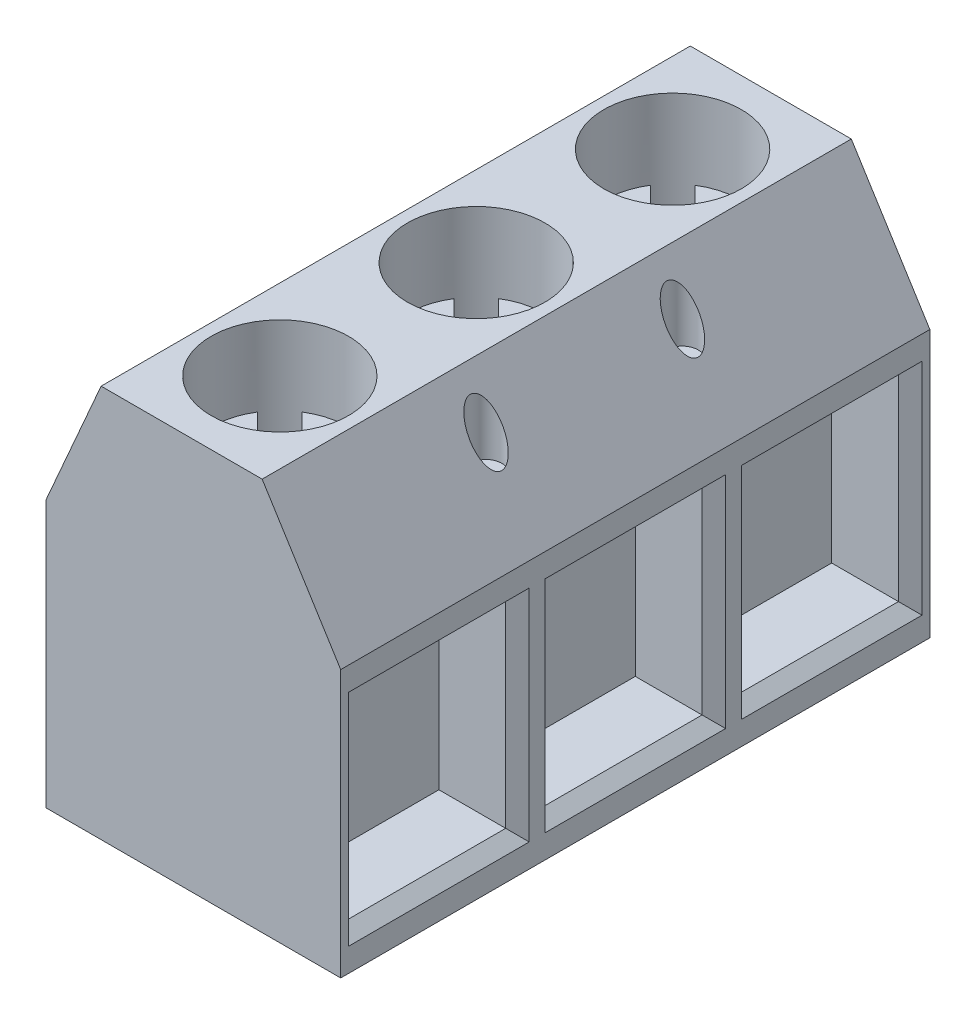
from build123d import *

# Parameters (mm, degrees)
BOSS_EXTRUDE1_DEPTH = 7.5
SKETCH2_W           = 1
SKETCH2_H           = 1
BOSS_EXTRUDE2_DEPTH = 1
SKETCH3_W           = 4
SKETCH3_H           = 5
CUT_EXTRUDE1_DEPTH  = 2
SKETCH4_R           = 1.75
SKETCH4_R_2         = 0.4
CUT_EXTRUDE2_DEPTH  = 2
CUT_EXTRUDE3_DEPTH  = 0.5
CHAMFER1_SIZE       = 0.3


with BuildPart() as part:
    # Sketch1 → Boss-Extrude1 (new body, symmetric)
    with BuildSketch(Plane.XY):
        Polygon((-3.75, 0), (3.75, 0), (3.75, 6.8), (1.75, 10), (-2.35, 10), (-3.75, 6.8), align=None)
    extrude(amount=BOSS_EXTRUDE1_DEPTH, both=True)

    # Sketch2 → Boss-Extrude2 (add)
    with BuildSketch(Plane.XZ):
        with Locations((0.45, 5)):
            Rectangle(SKETCH2_W, SKETCH2_H)
        with Locations((0.45, 0)):
            Rectangle(SKETCH2_W, SKETCH2_H)
        with Locations((0.45, -5)):
            Rectangle(SKETCH2_W, SKETCH2_H)
    extrude(amount=BOSS_EXTRUDE2_DEPTH)

    # Sketch3 → Cut-Extrude1 (cut)
    with BuildSketch(Plane(origin=(3.75, 0, 0), x_dir=(0, 0, -1), z_dir=(1, 0, 0))):
        with Locations((-5, 3.4)):
            Rectangle(SKETCH3_W, SKETCH3_H)
        with Locations((0, 3.4)):
            Rectangle(SKETCH3_W, SKETCH3_H)
        with Locations((5, 3.4)):
            Rectangle(SKETCH3_W, SKETCH3_H)
    extrude(amount=-CUT_EXTRUDE1_DEPTH, mode=Mode.SUBTRACT)

    # Sketch4 → Cut-Extrude2 (cut)
    with BuildSketch(Plane(origin=(0, 10, 0), x_dir=(1, 0, 0), z_dir=(0, 1, 0))):
        with Locations((-0.3, 5)):
            Circle(SKETCH4_R)
        with Locations((-0.3, 0)):
            Circle(SKETCH4_R)
        with Locations((-0.3, -5)):
            Circle(SKETCH4_R)
        with Locations((2.45, 2.5)):
            Circle(SKETCH4_R_2)
        with Locations((2.45, -2.5)):
            Circle(SKETCH4_R_2)
        with Locations((-3.05, 2.5)):
            Circle(SKETCH4_R_2)
        with Locations((-3.05, -2.5)):
            Circle(SKETCH4_R_2)
    extrude(amount=-CUT_EXTRUDE2_DEPTH, mode=Mode.SUBTRACT)

    # Sketch5 → Cut-Extrude3 (cut)
    with BuildSketch(Plane(origin=(0, 8, 0), x_dir=(1, 0, 0), z_dir=(0, 1, 0))):
        with BuildLine():
            Line((-1.221836, 1.487521), (-0.3, 0.565685))
            Line((-0.3, 0.565685), (0.124264, 0.989949))
            Line((0.124264, 0.989949), (0.689949, 0.424264))
            Line((0.689949, 0.424264), (0.265685, 0))
            Line((0.265685, 0), (1.187521, -0.921836))
            ThreePointArc((1.187521, -0.921836), (0.937437, -1.237437), (0.621836, -1.487521))
            Line((0.621836, -1.487521), (-0.3, -0.565685))
            Line((-0.3, -0.565685), (-0.724264, -0.989949))
            Line((-0.724264, -0.989949), (-1.289949, -0.424264))
            Line((-1.289949, -0.424264), (-0.865685, 0))
            Line((-0.865685, 0), (-1.787521, 0.921836))
            ThreePointArc((-1.787521, 0.921836), (-1.537437, 1.237437), (-1.221836, 1.487521))
        make_face()
        with BuildLine():
            Line((-1.221836, 6.487521), (-0.3, 5.565685))
            Line((-0.3, 5.565685), (0.124264, 5.989949))
            Line((0.124264, 5.989949), (0.689949, 5.424264))
            Line((0.689949, 5.424264), (0.265685, 5))
            Line((0.265685, 5), (1.187521, 4.078164))
            ThreePointArc((1.187521, 4.078164), (0.937437, 3.762563), (0.621836, 3.512479))
            Line((0.621836, 3.512479), (-0.3, 4.434315))
            Line((-0.3, 4.434315), (-0.724264, 4.010051))
            Line((-0.724264, 4.010051), (-1.289949, 4.575736))
            Line((-1.289949, 4.575736), (-0.865685, 5))
            Line((-0.865685, 5), (-1.787521, 5.921836))
            ThreePointArc((-1.787521, 5.921836), (-1.537437, 6.237437), (-1.221836, 6.487521))
        make_face()
        with BuildLine():
            Line((-1.221836, -3.512479), (-0.3, -4.434315))
            Line((-0.3, -4.434315), (0.124264, -4.010051))
            Line((0.124264, -4.010051), (0.689949, -4.575736))
            Line((0.689949, -4.575736), (0.265685, -5))
            Line((0.265685, -5), (1.187521, -5.921836))
            ThreePointArc((1.187521, -5.921836), (0.937437, -6.237437), (0.621836, -6.487521))
            Line((0.621836, -6.487521), (-0.3, -5.565685))
            Line((-0.3, -5.565685), (-0.724264, -5.989949))
            Line((-0.724264, -5.989949), (-1.289949, -5.424264))
            Line((-1.289949, -5.424264), (-0.865685, -5))
            Line((-0.865685, -5), (-1.787521, -4.078164))
            ThreePointArc((-1.787521, -4.078164), (-1.537437, -3.762563), (-1.221836, -3.512479))
        make_face()
    extrude(amount=-CUT_EXTRUDE3_DEPTH, mode=Mode.SUBTRACT)

    # Chamfer1
    chamfer1_edges = [part.edges().sort_by_distance(p)[0] for p in [
        (3.75, 3.4, 7),
        (3.75, 0.9, 5),
        (3.75, 3.4, 3),
        (3.75, 5.9, 5),
        (3.75, 3.4, 2),
        (3.75, 0.9, 0),
        (3.75, 3.4, -2),
        (3.75, 5.9, 0),
        (3.75, 3.4, -3),
        (3.75, 0.9, -5),
        (3.75, 3.4, -7),
        (3.75, 5.9, -5),
    ]]
    chamfer(chamfer1_edges, length=CHAMFER1_SIZE)


solid = part.part
